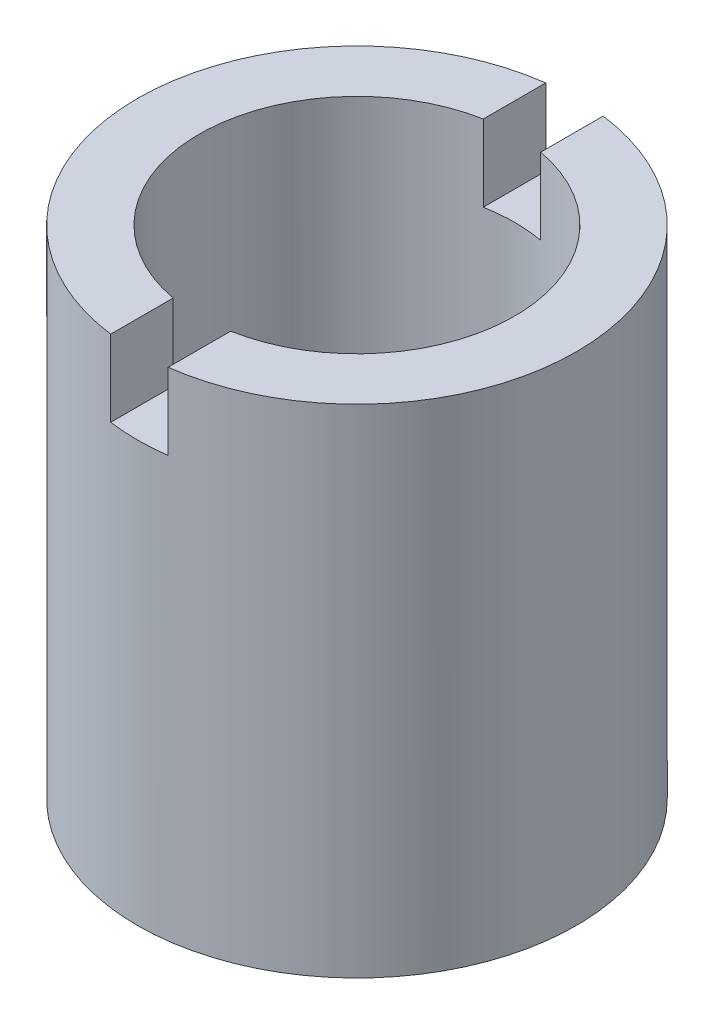
from build123d import *

# Parameters (mm, degrees)
SKETCH2_R               = 9.1186
SKETCH2_R_2             = 6.5532
BOSS_EXTRUDE1_DEPTH     = 20.6502
CUT_EXTRUDE1_DEPTH      = 1
CUT_EXTRUDE1_DEPTH_BACK = 3.175


with BuildPart() as part:
    # Sketch2 → Boss-Extrude1 (new body)
    with BuildSketch(Plane(origin=(0, 0, 0), x_dir=(1, 0, 0), z_dir=(0, 1, 0))):
        Circle(SKETCH2_R)
        Circle(SKETCH2_R_2, mode=Mode.SUBTRACT)
    extrude(amount=BOSS_EXTRUDE1_DEPTH)

    # Sketch3 → Cut-Extrude1 (cut, two sides)
    with BuildSketch(Plane(origin=(0, 20.6502, 0), x_dir=(1, 0, 0), z_dir=(0, 1, 0))) as cut_extrude1_sk:
        with BuildLine():
            ThreePointArc((-1.1938, 6.443544972), (0, 6.5532), (1.1938, 6.443544972))
            Line((1.1938, 6.443544972), (1.1938, 9.040116566))
            ThreePointArc((1.1938, 9.040116566), (0, 9.1186), (-1.1938, 9.040116566))
            Line((-1.1938, 9.040116566), (-1.1938, 6.443544972))
        make_face()
        with BuildLine():
            Line((1.1938, -9.040116566), (1.1938, -6.443544972))
            ThreePointArc((1.1938, -6.443544972), (0, -6.5532), (-1.1938, -6.443544972))
            Line((-1.1938, -6.443544972), (-1.1938, -9.040116566))
            ThreePointArc((-1.1938, -9.040116566), (0, -9.1186), (1.1938, -9.040116566))
        make_face()
    extrude(amount=CUT_EXTRUDE1_DEPTH, mode=Mode.SUBTRACT)
    extrude(cut_extrude1_sk.sketch, amount=-CUT_EXTRUDE1_DEPTH_BACK, mode=Mode.SUBTRACT)


solid = part.part
